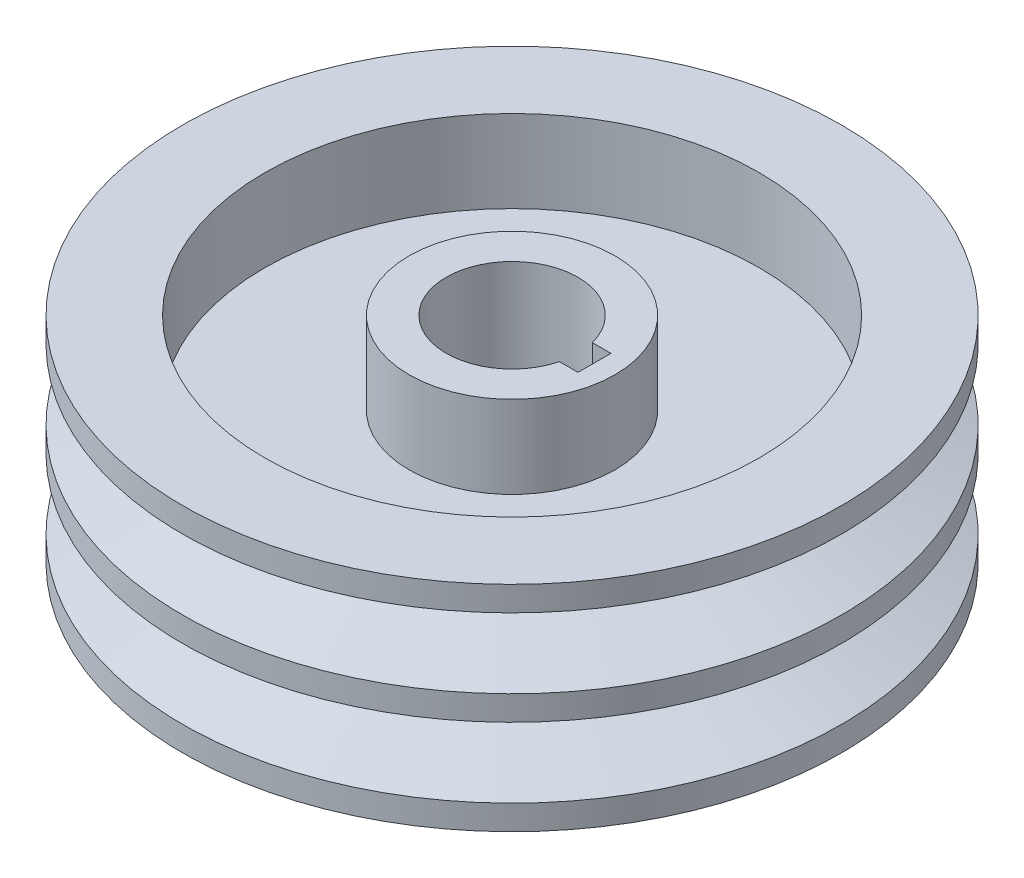
from build123d import *

# Parameters (mm, degrees)
SKETCH_2_W          = 10
SKETCH_2_H          = 4
CUT_EXTRUDE_1_DEPTH = 27


with BuildPart() as part:
    # 草圖1 → 旋轉1 (revolve)
    with BuildSketch(Plane.XY):
        Polygon((30, -13), (30, -3), (12.5, -3), (12.5, -13), (8, -13), (8, 13), (12.5, 13), (12.5, 3), (30, 3), (30, 13), (40, 13), (40, 10), (32, 7.088238126), (32, 4.411761874), (40, 1.5), (40, -1.5), (32, -4.411761874), (32, -7.088238126), (40, -10), (40, -13), align=None)
    revolve(axis=Axis((0, 0, 0), (0, 1, 0)))

    # 草圖2 → 除料-伸長1 (cut, through all)
    with BuildSketch(Plane(origin=(0, 13, 0), x_dir=(1, 0, 0), z_dir=(0, 1, 0))):
        with Locations((5, 0)):
            Rectangle(SKETCH_2_W, SKETCH_2_H)
    extrude(amount=-CUT_EXTRUDE_1_DEPTH, mode=Mode.SUBTRACT)


solid = part.part
